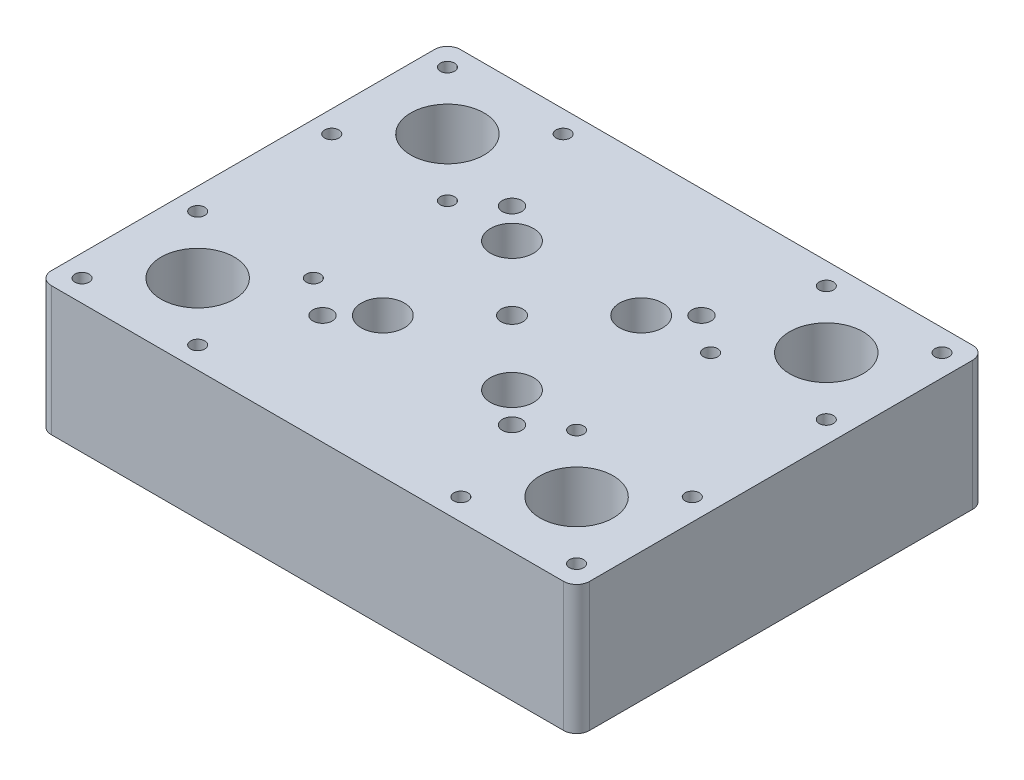
from build123d import *

# Parameters (mm, degrees)
SKETCH1_W                      = 125
SKETCH1_H                      = 95
SKETCH1_R                      = 8.5
BOSS_EXTRUDE1_DEPTH            = 30
M4X0_7_TAPPED_HOLE1_AT_2_COUNT = 2
M4X0_7_TAPPED_HOLE1_AT_2_PITCH = 26.870057685
M4X0_7_TAPPED_HOLE1_AT_3_COUNT = 2
M4X0_7_TAPPED_HOLE1_AT_3_PITCH = 38
M4X0_7_TAPPED_HOLE1_AT_4_COUNT = 2
M4X0_7_TAPPED_HOLE1_AT_4_PITCH = 26.870057685
LPATTERN1_COUNT                = 2
LPATTERN1_PITCH                = 88
LPATTERN1_COUNT_DIR2           = 2
LPATTERN1_PITCH_DIR2           = 58
SKETCH5_W                      = 60
SKETCH5_H                      = 60
CUT_EXTRUDE1_DEPTH             = 20
FILLET1_R                      = 7
FILLET2_R                      = 3
F_1_4_20_TAPPED_HOLE1_D        = 5.1054
SKETCH8_R                      = 5
CUT_EXTRUDE2_DEPTH             = 31
M4_CLEARANCE_HOLE1_D           = 4.5


with BuildPart() as part:
    # Sketch1 → Boss-Extrude1 (new body)
    with BuildSketch(Plane(origin=(0, 0, 0), x_dir=(1, 0, 0), z_dir=(0, 1, 0))):
        Rectangle(SKETCH1_W, SKETCH1_H)
        with Locations((-44, 29)):
            Circle(SKETCH1_R, mode=Mode.SUBTRACT)
        with Locations((44, 29)):
            Circle(SKETCH1_R, mode=Mode.SUBTRACT)
        with Locations((44, -29)):
            Circle(SKETCH1_R, mode=Mode.SUBTRACT)
        with Locations((-44, -29)):
            Circle(SKETCH1_R, mode=Mode.SUBTRACT)
    extrude(amount=BOSS_EXTRUDE1_DEPTH)

    # Sketch2 → M4x0.7 Tapped Hole1 (revolve, cut)
    with BuildSketch(Plane(origin=(-57.435028843, 30, -42.435028843), x_dir=(0, 0, 1), z_dir=(1, 0, 0))):
        Polygon((0, 0), (0, 8.991420021), (1.65, 8), (1.65, 0), align=None)
    m4x0_7_tapped_hole1 = revolve(axis=Axis((-57.435028843, 36.35, -42.435028843), (0, -1, 0)), mode=Mode.SUBTRACT)

    # M4x0.7 Tapped Hole1 at 2: M4x0.7 Tapped Hole1 ×2
    with Locations(*[(i * M4X0_7_TAPPED_HOLE1_AT_2_PITCH, 0, 0) for i in range(1, M4X0_7_TAPPED_HOLE1_AT_2_COUNT)]):
        add(m4x0_7_tapped_hole1, mode=Mode.SUBTRACT)

    # M4x0.7 Tapped Hole1 at 3: M4x0.7 Tapped Hole1 ×2
    with Locations(*[Vector(0.707106781, 0, 0.707106781) * (i * M4X0_7_TAPPED_HOLE1_AT_3_PITCH) for i in range(1, M4X0_7_TAPPED_HOLE1_AT_3_COUNT)]):
        add(m4x0_7_tapped_hole1, mode=Mode.SUBTRACT)

    # M4x0.7 Tapped Hole1 at 4: M4x0.7 Tapped Hole1 ×2
    with Locations(*[(0, 0, i * M4X0_7_TAPPED_HOLE1_AT_4_PITCH) for i in range(1, M4X0_7_TAPPED_HOLE1_AT_4_COUNT)]):
        add(m4x0_7_tapped_hole1, mode=Mode.SUBTRACT)

    # LPattern1: M4x0.7 Tapped Hole1 2 × 2
    with Locations(*[(i * LPATTERN1_PITCH, 0, j * LPATTERN1_PITCH_DIR2) for i in range(LPATTERN1_COUNT) for j in range(LPATTERN1_COUNT_DIR2) if (i, j) != (0, 0)]):
        add(m4x0_7_tapped_hole1, mode=Mode.SUBTRACT)

    # LPattern1 copy 1 sketch → LPattern1 copy 1 (revolve, cut)
    with BuildSketch(Plane(origin=(-30.564971157, 30, 15.564971157), x_dir=(0, 0, 1), z_dir=(1, 0, 0))):
        Polygon((0, 0), (0, 8.991420021), (1.65, 8), (1.65, 0), align=None)
    revolve(axis=Axis((-30.564971157, 36.35, 15.564971157), (0, -1, 0)), mode=Mode.SUBTRACT)

    # LPattern1 copy 2 sketch → LPattern1 copy 2 (revolve, cut)
    with BuildSketch(Plane(origin=(57.435028843, 30, -42.435028843), x_dir=(0, 0, 1), z_dir=(1, 0, 0))):
        Polygon((0, 0), (0, 8.991420021), (1.65, 8), (1.65, 0), align=None)
    revolve(axis=Axis((57.435028843, 36.35, -42.435028843), (0, -1, 0)), mode=Mode.SUBTRACT)

    # LPattern1 copy 3 sketch → LPattern1 copy 3 (revolve, cut)
    with BuildSketch(Plane(origin=(57.435028843, 30, 15.564971157), x_dir=(0, 0, 1), z_dir=(1, 0, 0))):
        Polygon((0, 0), (0, 8.991420021), (1.65, 8), (1.65, 0), align=None)
    revolve(axis=Axis((57.435028843, 36.35, 15.564971157), (0, -1, 0)), mode=Mode.SUBTRACT)

    # LPattern1 copy 4 sketch → LPattern1 copy 4 (revolve, cut)
    with BuildSketch(Plane(origin=(-30.564971157, 30, 42.435028843), x_dir=(0, 0, 1), z_dir=(1, 0, 0))):
        Polygon((0, 0), (0, 8.991420021), (1.65, 8), (1.65, 0), align=None)
    revolve(axis=Axis((-30.564971157, 36.35, 42.435028843), (0, -1, 0)), mode=Mode.SUBTRACT)

    # LPattern1 copy 5 sketch → LPattern1 copy 5 (revolve, cut)
    with BuildSketch(Plane(origin=(57.435028843, 30, -15.564971157), x_dir=(0, 0, 1), z_dir=(1, 0, 0))):
        Polygon((0, 0), (0, 8.991420021), (1.65, 8), (1.65, 0), align=None)
    revolve(axis=Axis((57.435028843, 36.35, -15.564971157), (0, -1, 0)), mode=Mode.SUBTRACT)

    # LPattern1 copy 6 sketch → LPattern1 copy 6 (revolve, cut)
    with BuildSketch(Plane(origin=(57.435028843, 30, 42.435028843), x_dir=(0, 0, 1), z_dir=(1, 0, 0))):
        Polygon((0, 0), (0, 8.991420021), (1.65, 8), (1.65, 0), align=None)
    revolve(axis=Axis((57.435028843, 36.35, 42.435028843), (0, -1, 0)), mode=Mode.SUBTRACT)

    # LPattern1 copy 7 sketch → LPattern1 copy 7 (revolve, cut)
    with BuildSketch(Plane(origin=(-57.435028843, 30, 42.435028843), x_dir=(0, 0, 1), z_dir=(1, 0, 0))):
        Polygon((0, 0), (0, 8.991420021), (1.65, 8), (1.65, 0), align=None)
    revolve(axis=Axis((-57.435028843, 36.35, 42.435028843), (0, -1, 0)), mode=Mode.SUBTRACT)

    # LPattern1 copy 8 sketch → LPattern1 copy 8 (revolve, cut)
    with BuildSketch(Plane(origin=(30.564971157, 30, -15.564971157), x_dir=(0, 0, 1), z_dir=(1, 0, 0))):
        Polygon((0, 0), (0, 8.991420021), (1.65, 8), (1.65, 0), align=None)
    revolve(axis=Axis((30.564971157, 36.35, -15.564971157), (0, -1, 0)), mode=Mode.SUBTRACT)

    # LPattern1 copy 9 sketch → LPattern1 copy 9 (revolve, cut)
    with BuildSketch(Plane(origin=(30.564971157, 30, 42.435028843), x_dir=(0, 0, 1), z_dir=(1, 0, 0))):
        Polygon((0, 0), (0, 8.991420021), (1.65, 8), (1.65, 0), align=None)
    revolve(axis=Axis((30.564971157, 36.35, 42.435028843), (0, -1, 0)), mode=Mode.SUBTRACT)

    # Sketch5 → Cut-Extrude1 (cut)
    with BuildSketch(Plane.XZ):
        Rectangle(SKETCH5_W, SKETCH5_H)
    extrude(amount=-CUT_EXTRUDE1_DEPTH, mode=Mode.SUBTRACT)

    # Fillet1
    fillet1_edges = [part.edges().sort_by_distance(p)[0] for p in [
        (-30, 10, -30),
        (-30, 10, 30),
        (30, 10, 30),
        (30, 10, -30),
    ]]
    fillet(fillet1_edges, radius=FILLET1_R)

    # Fillet2
    fillet2_edges = [part.edges().sort_by_distance(p)[0] for p in [
        (-62.5, 15, -47.5),
        (62.5, 15, -47.5),
        (62.5, 15, 47.5),
        (-62.5, 15, 47.5),
    ]]
    fillet(fillet2_edges, radius=FILLET2_R)

    # 1/4-20 Tapped Hole1 (through all)
    with Locations(Plane(origin=(0, 20, 0), x_dir=(-1, 0, 0), z_dir=(0, -1, 0))):
        with Locations((0, 0)):
            Hole(F_1_4_20_TAPPED_HOLE1_D / 2)

    # Sketch8 → Cut-Extrude2 (cut, through all)
    with BuildSketch(Plane.XZ):
        with Locations((-15, 15)):
            Circle(SKETCH8_R)
        with Locations((-15, -15)):
            Circle(SKETCH8_R)
        with Locations((15, 15)):
            Circle(SKETCH8_R)
        with Locations((15, -15)):
            Circle(SKETCH8_R)
    extrude(amount=-CUT_EXTRUDE2_DEPTH, mode=Mode.SUBTRACT)

    # M4 Clearance Hole1 (through all)
    with Locations(Plane(origin=(0, 20, 0), x_dir=(-1, 0, 0), z_dir=(0, -1, 0))):
        with Locations((22, -22), (-22, -22), (-22, 22), (22, 22)):
            Hole(M4_CLEARANCE_HOLE1_D / 2)


solid = part.part
